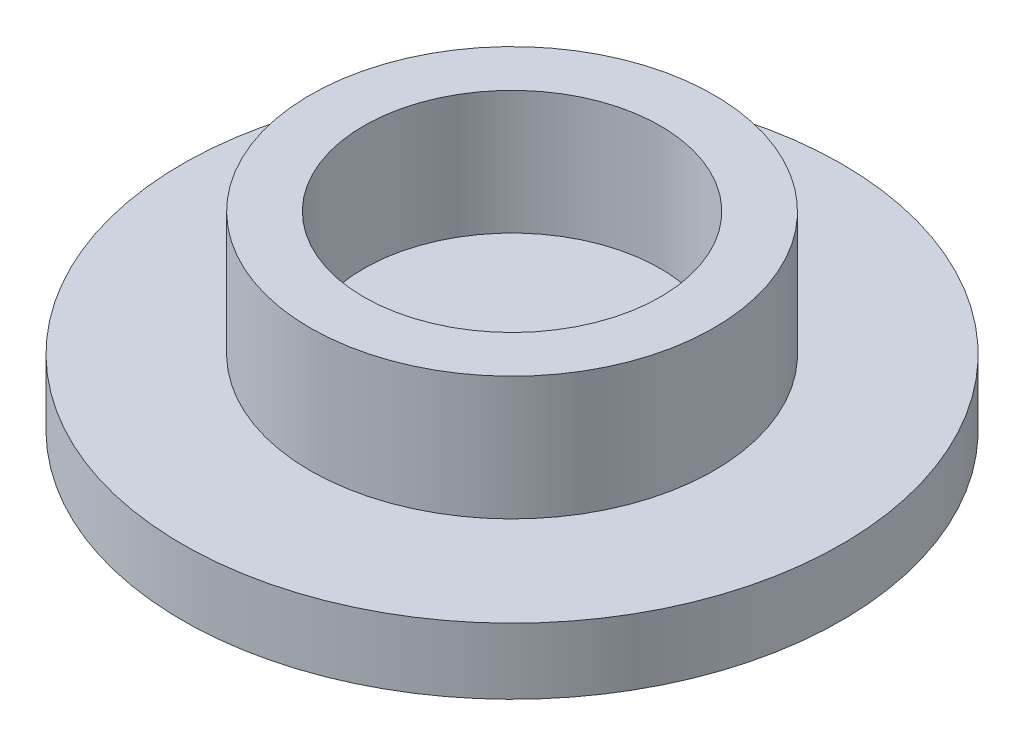
from build123d import *

# Parameters (mm, degrees)
SKETCH1_R           = 2.45
SKETCH1_R_2         = 1.8
BOSS_EXTRUDE1_DEPTH = 1.5
SKETCH2_R           = 4
BOSS_EXTRUDE2_DEPTH = 0.8


with BuildPart() as part:
    # Sketch1 → Boss-Extrude1 (new body)
    with BuildSketch(Plane(origin=(0, 0, 0), x_dir=(1, 0, 0), z_dir=(0, 1, 0))):
        Circle(SKETCH1_R)
        Circle(SKETCH1_R_2, mode=Mode.SUBTRACT)
    extrude(amount=BOSS_EXTRUDE1_DEPTH)

    # Sketch2 → Boss-Extrude2 (add)
    with BuildSketch(Plane.XZ):
        Circle(SKETCH2_R)
    extrude(amount=BOSS_EXTRUDE2_DEPTH)


solid = part.part
